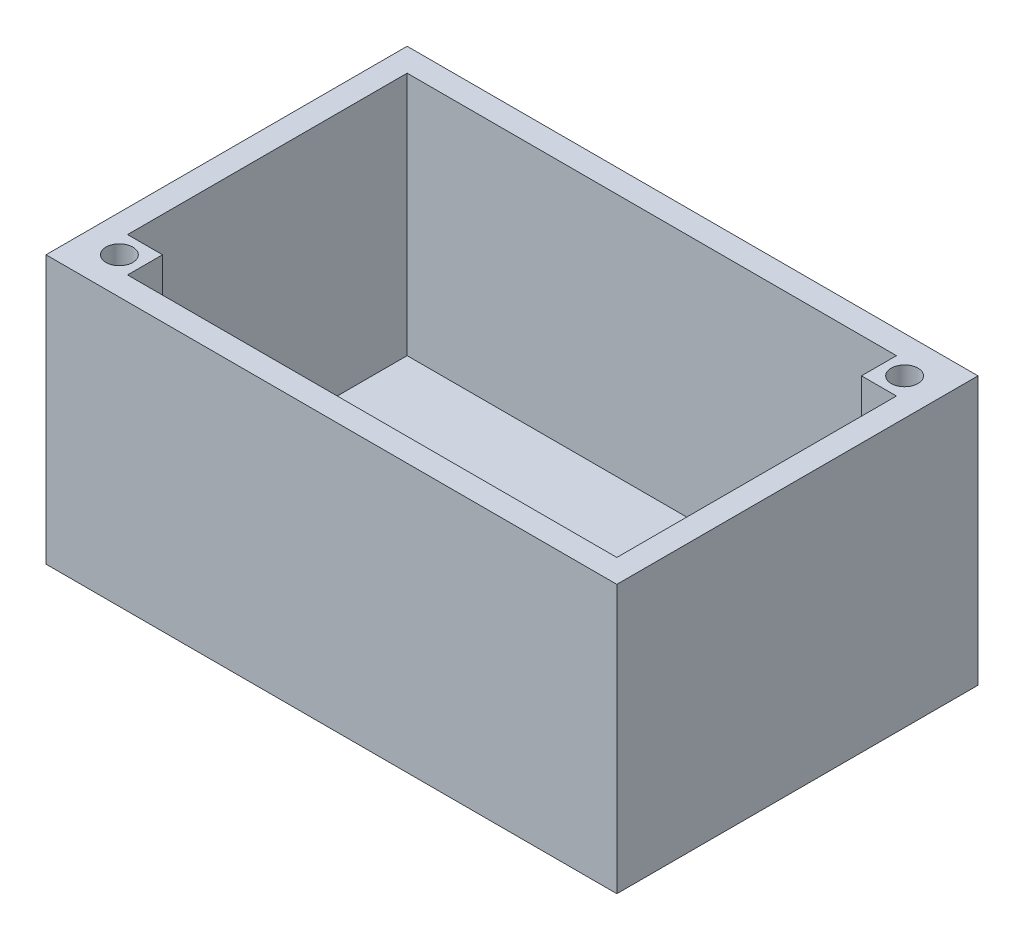
from build123d import *

# Parameters (mm, degrees)
SKETCH1_W           = 62.23
SKETCH1_H           = 29.21
BOSS_EXTRUDE1_DEPTH = 39.37
SHELL1_T            = -2.54
BOSS_EXTRUDE2_REACH = 31.21


with BuildPart() as part:
    # Sketch1 → Boss-Extrude1 (new body)
    with BuildSketch(Plane.XY):
        with Locations((31.115, 14.605)):
            Rectangle(SKETCH1_W, SKETCH1_H)
    extrude(amount=-BOSS_EXTRUDE1_DEPTH)

    # Shell1
    shell1_openings = [part.faces().sort_by_distance(p)[0] for p in [
        (31.115, 29.21, -19.685),
    ]]
    offset(amount=SHELL1_T, openings=shell1_openings, kind=Kind.INTERSECTION)

    # Sketch2 → Boss-Extrude2 (add, up to next)
    with BuildSketch(Plane(origin=(0, 29.21, 0), x_dir=(1, 0, 0), z_dir=(0, 1, 0)), mode=Mode.PRIVATE) as boss_extrude2_sk1:
        with BuildLine():
            Line((2.54, 2.54), (4.0005, 2.54))
            ThreePointArc((4.0005, 2.54), (2.967770546, 2.967770546), (2.54, 4.0005))
            Line((2.54, 4.0005), (2.54, 2.54))
        make_face()
    boss_extrude2_tool1 = extrude(boss_extrude2_sk1.sketch, amount=-BOSS_EXTRUDE2_REACH, mode=Mode.PRIVATE) - part.part
    add(boss_extrude2_tool1.solids().sort_by_distance((2.866229, 29.21, -2.866229))[0])
    # Sketch2 → Boss-Extrude2 (add, up to next)
    with BuildSketch(Plane(origin=(0, 29.21, 0), x_dir=(1, 0, 0), z_dir=(0, 1, 0)), mode=Mode.PRIVATE) as boss_extrude2_sk2:
        with BuildLine():
            ThreePointArc((58.2295, 36.83), (59.262229454, 36.402229454), (59.69, 35.3695))
            Line((59.69, 35.3695), (59.69, 36.83))
            Line((59.69, 36.83), (58.2295, 36.83))
        make_face()
    boss_extrude2_tool2 = extrude(boss_extrude2_sk2.sketch, amount=-BOSS_EXTRUDE2_REACH, mode=Mode.PRIVATE) - part.part
    add(boss_extrude2_tool2.solids().sort_by_distance((59.363771, 29.21, -36.503771))[0])
    # Sketch2 → Boss-Extrude2 (add, up to next)
    with BuildSketch(Plane(origin=(0, 29.21, 0), x_dir=(1, 0, 0), z_dir=(0, 1, 0)), mode=Mode.PRIVATE) as boss_extrude2_sk3:
        with BuildLine():
            Line((55.88, 33.02), (59.69, 33.02))
            Line((59.69, 33.02), (59.69, 35.3695))
            ThreePointArc((59.69, 35.3695), (57.196770546, 34.336770546), (58.2295, 36.83))
            Line((58.2295, 36.83), (55.88, 36.83))
            Line((55.88, 36.83), (55.88, 33.02))
        make_face()
    boss_extrude2_tool3 = extrude(boss_extrude2_sk3.sketch, amount=-BOSS_EXTRUDE2_REACH, mode=Mode.PRIVATE) - part.part
    add(boss_extrude2_tool3.solids().sort_by_distance((57.05475, 29.21, -36.776118))[0])
    # Sketch2 → Boss-Extrude2 (add, up to next)
    with BuildSketch(Plane(origin=(0, 29.21, 0), x_dir=(1, 0, 0), z_dir=(0, 1, 0)), mode=Mode.PRIVATE) as boss_extrude2_sk4:
        with BuildLine():
            Line((4.0005, 2.54), (6.35, 2.54))
            Line((6.35, 2.54), (6.35, 6.35))
            Line((6.35, 6.35), (2.54, 6.35))
            Line((2.54, 6.35), (2.54, 4.0005))
            ThreePointArc((2.54, 4.0005), (4.0005, 5.461), (5.461, 4.0005))
            ThreePointArc((5.461, 4.0005), (5.033229454, 2.967770546), (4.0005, 2.54))
        make_face()
    boss_extrude2_tool4 = extrude(boss_extrude2_sk4.sketch, amount=-BOSS_EXTRUDE2_REACH, mode=Mode.PRIVATE) - part.part
    add(boss_extrude2_tool4.solids().sort_by_distance((4.0005, 29.21, -5.514882))[0])


solid = part.part
